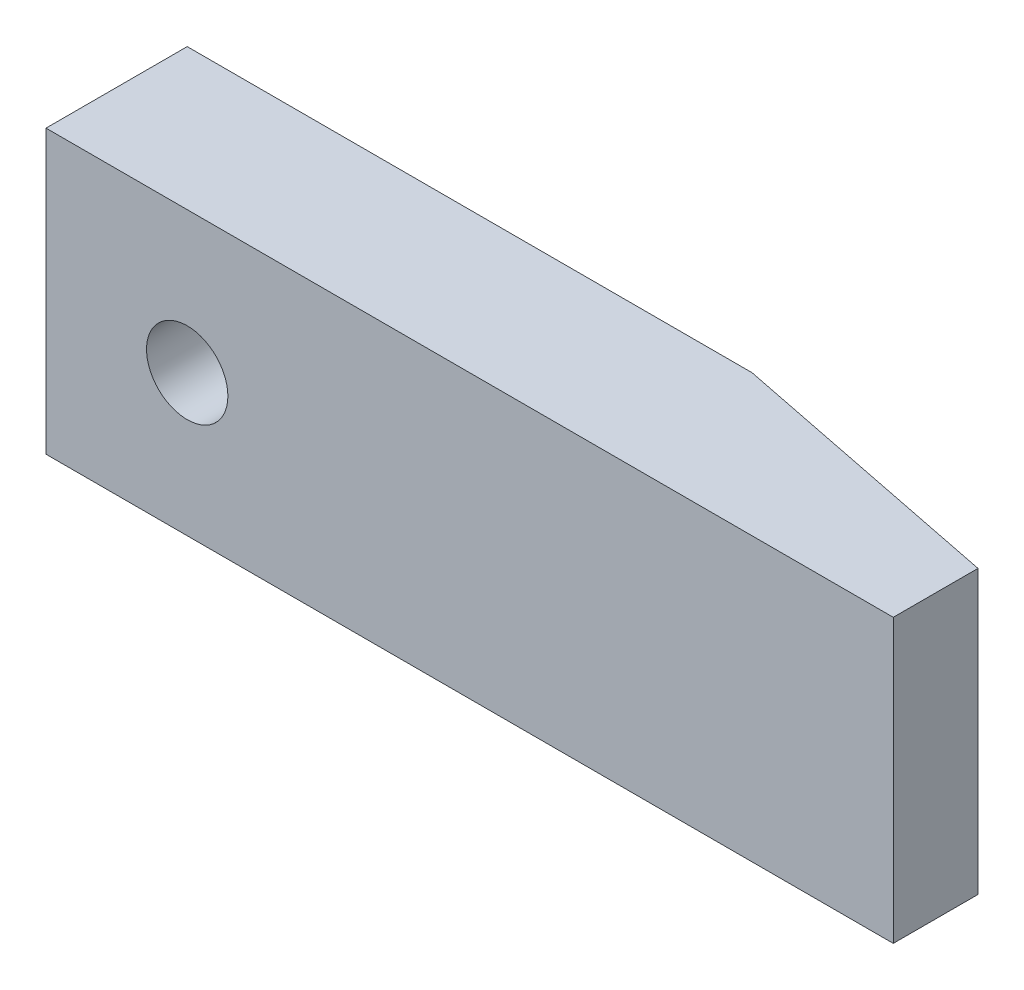
from build123d import *

# Parameters (mm, degrees)
SKETCH1_W                   = 38.1
SKETCH1_H                   = 6.35
BOSS_EXTRUDE1_DEPTH         = 6.35
F_27_0_144_DIAMETER_HOLE1_D = 3.6576
CUT_EXTRUDE1_DEPTH          = 13.7


with BuildPart() as part:
    # Sketch1 → Boss-Extrude1 (new body, symmetric)
    with BuildSketch(Plane(origin=(0, 0, 0), x_dir=(-1, 0, 0), z_dir=(0, 1, 0))):
        Rectangle(SKETCH1_W, SKETCH1_H)
    extrude(amount=BOSS_EXTRUDE1_DEPTH, both=True)

    # #27 (0.144) Diameter Hole1 (through all)
    with Locations(Plane.XY.offset(3.175)):
        with Locations((-12.7, 0)):
            Hole(F_27_0_144_DIAMETER_HOLE1_D / 2)

    # Sketch5 → Cut-Extrude1 (cut, through all)
    with BuildSketch(Plane.XZ.offset(6.35)):
        Polygon((19.05, -0.635), (6.35, -3.175), (19.05, -3.175), align=None)
    extrude(amount=-CUT_EXTRUDE1_DEPTH, mode=Mode.SUBTRACT)


solid = part.part
